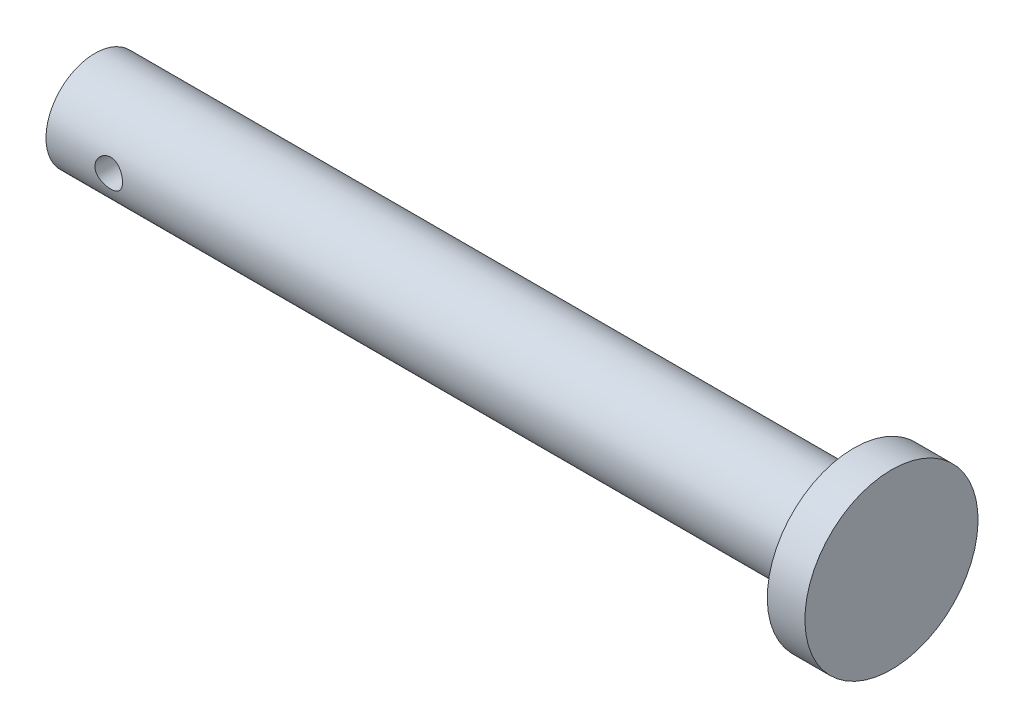
from build123d import *

# Parameters (mm, degrees)
CUT_EXTRUDE1_DEPTH      = 31.748699159
CUT_EXTRUDE1_DEPTH_BACK = 31.748699159
SKETCH2_3_R             = 1.1
SKETCH3_R               = 6.9
BOSS_EXTRUDE1_DEPTH     = 3


with BuildPart() as part:
    # Sketch2 → Revolve2 (revolve)
    with BuildSketch(Plane.XY):
        with BuildLine():
            Line((30.25, 0), (-24.15, 0))
            ThreePointArc((-24.15, 0), (-25.25, -1.1), (-26.35, 0))
            Line((-26.35, 0), (-30.25, 0))
            Line((-30.25, 0), (-30.25, -3.9))
            Line((-30.25, -3.9), (30.25, -3.9))
            Line((30.25, -3.9), (30.25, 0))
        make_face()
    revolve(axis=Axis((-30.25, 0, 0), (1, 0, 0)))

    # Sketch2_3 → Cut-Extrude1 (cut, two sides: drawn at the far end of the back side and taken through both)
    with BuildSketch(Plane.XY.offset(-CUT_EXTRUDE1_DEPTH_BACK)):
        with Locations((-25.25, 0)):
            Circle(SKETCH2_3_R)
    extrude(amount=CUT_EXTRUDE1_DEPTH + CUT_EXTRUDE1_DEPTH_BACK, mode=Mode.SUBTRACT)

    # Sketch3 → Boss-Extrude1 (add)
    with BuildSketch(Plane(origin=(30.25, 0, 0), x_dir=(0, 0, -1), z_dir=(1, 0, 0))):
        Circle(SKETCH3_R)
    extrude(amount=BOSS_EXTRUDE1_DEPTH)


solid = part.part
